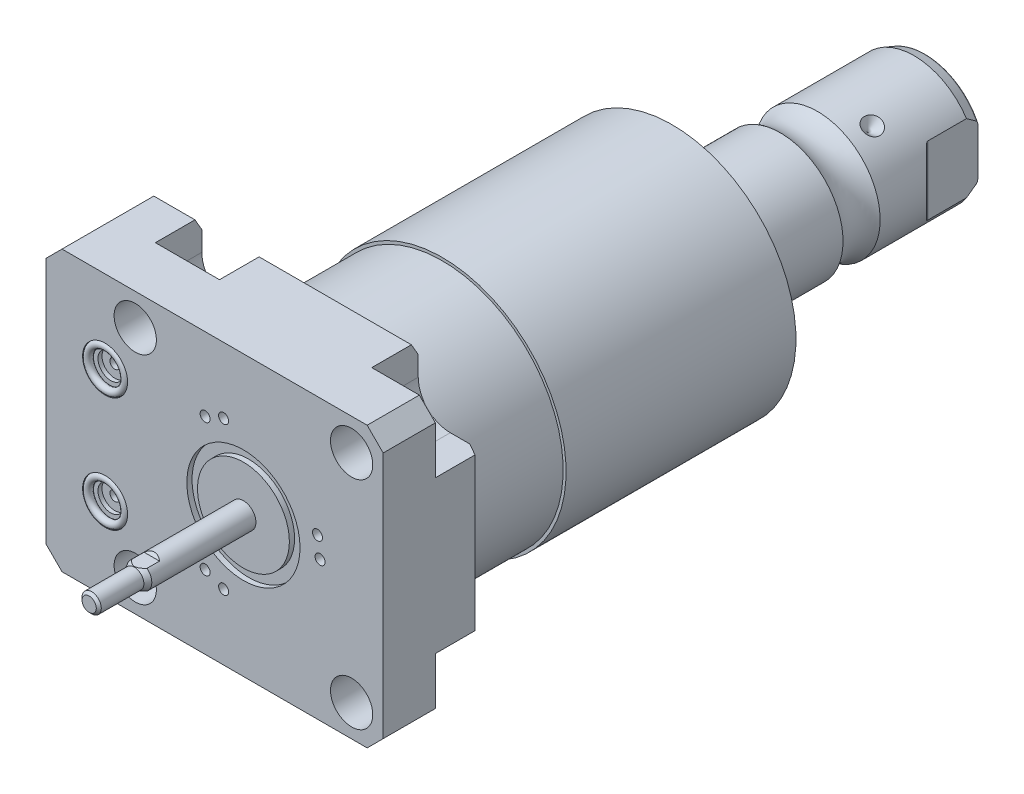
from build123d import *

# Parameters (mm, degrees)
SKETCH1_W                = 85.4964
SKETCH1_H                = 70.866
EXTRUDE1_DEPTH           = 25.019
SKETCH2_R                = 5.3594
CUT_EXTRUDE1_DEPTH       = 27.5209
LPATTERN1_COUNT          = 2
LPATTERN1_PITCH          = 54.864
LPATTERN1_COUNT_DIR2     = 2
LPATTERN1_PITCH_DIR2     = 54.864
CUT_EXTRUDE2_DEPTH       = 11.7856
SKETCH6_R                = 5.7023
CUT_EXTRUDE3_DEPTH       = 1.4478
SKETCH7_R                = 3.2512
CUT_EXTRUDE4_DEPTH       = 1.016
SKETCH8_R                = 1.2446
CUT_EXTRUDE5_DEPTH       = 11.9888
SKETCH9_R                = 0.9271
CHAMFER1_SIZE            = 4.064
CHAMFER2_SIZE            = 3.0226
CHAMFER2_SIZE2           = 1.745098924
SKETCH14_R               = 31.3944
EXTRUDE2_DEPTH           = 86.995
SKETCH15_OUTSIDE_W       = 119.1
SKETCH15_OUTSIDE_H       = 104.47
SKETCH15_OUTSIDE_R       = 30.6578
CUT_EXTRUDE9_DEPTH       = 25.4
CIRPATTERN1_COUNT        = 3
FILLET1_R                = 0.635
CUT_EXTRUDE12_DEPTH      = 36.433
CUT_EXTRUDE12_DEPTH_BACK = 36.433
SKETCH28_W               = 1.3208
SKETCH28_H               = 2.7051
CUT_EXTRUDE13_DEPTH      = 3.81
SKETCH30_R               = 1.27
CUT_EXTRUDE14_DEPTH      = 7.62


with BuildPart() as part:
    # Sketch1 → Extrude1 (new body)
    with BuildSketch(Plane.XY):
        with Locations((-7.3152, 0)):
            Rectangle(SKETCH1_W, SKETCH1_H)
    extrude(amount=EXTRUDE1_DEPTH)

    # Sketch2 → Cut-Extrude1 (cut)
    with BuildSketch(Plane(origin=(0, 0, 0), x_dir=(-1, 0, 0), z_dir=(0, 0, -1))):
        with Locations((-27.432, -27.432)):
            Circle(SKETCH2_R)
    cut_extrude1 = extrude(amount=-CUT_EXTRUDE1_DEPTH, mode=Mode.SUBTRACT)

    # LPattern1: Cut-Extrude1 2 × 2
    with Locations(*[(-j * LPATTERN1_PITCH_DIR2, i * LPATTERN1_PITCH, 0) for i in range(LPATTERN1_COUNT) for j in range(LPATTERN1_COUNT_DIR2) if (i, j) != (0, 0)]):
        add(cut_extrude1, mode=Mode.SUBTRACT)

    # Sketch3 → Cut-Extrude2 (cut)
    with BuildSketch(Plane(origin=(0, 0, 0), x_dir=(-1, 0, 0), z_dir=(0, 0, -1))):
        with BuildLine():
            Line((-27.432, -19.304), (-35.433, -19.304))
            Line((-35.433, -19.304), (-35.433, -35.433))
            Line((-35.433, -35.433), (-19.304, -35.433))
            Line((-19.304, -35.433), (-19.304, -27.432))
            ThreePointArc((-19.304, -27.432), (-21.684636083, -21.684636083), (-27.432, -19.304))
        make_face()
        with BuildLine():
            Line((-35.433, 19.304), (-35.433, 35.433))
            Line((-35.433, 35.433), (-19.304, 35.433))
            Line((-19.304, 35.433), (-19.304, 27.432))
            ThreePointArc((-19.304, 27.432), (-21.684636083, 21.684636083), (-27.432, 19.304))
            Line((-27.432, 19.304), (-35.433, 19.304))
        make_face()
        with BuildLine():
            Line((19.304, 35.433), (19.304, 27.432))
            ThreePointArc((19.304, 27.432), (27.432, 19.304), (35.56, 27.432))
            Line((35.56, 27.432), (35.56, 35.433))
            Line((35.56, 35.433), (19.304, 35.433))
        make_face()
        with BuildLine():
            Line((35.56, -35.433), (19.304, -35.433))
            Line((19.304, -35.433), (19.304, -27.432))
            ThreePointArc((19.304, -27.432), (27.432, -19.304), (35.56, -27.432))
            Line((35.56, -27.432), (35.56, -35.433))
        make_face()
    extrude(amount=-CUT_EXTRUDE2_DEPTH, mode=Mode.SUBTRACT)

    # S2D0007 → Cut-Revolve1 (revolve, cut)
    with BuildSketch(Plane(origin=(-55.5498, -13.0048, 12.5222), x_dir=(0, 1, 0), z_dir=(0, 0, 1)), mode=Mode.PRIVATE) as cut_revolve1_sk:
        Polygon((0, -5.4864), (10.4775, -5.4864), (10.4775, -5.7404), (6.1849, -5.7404), (5.642306865, -8.2931), (4.9784, -8.957006865), (4.9784, -19.7104), (0, -19.7104), align=None)
    cut_revolve1 = revolve(cut_revolve1_sk.sketch.rotate(Axis((-35.077219214, -13.0048, 12.5222), (-1, 0, 0)), 90), axis=Axis((-35.077219214, -13.0048, 12.5222), (-1, 0, 0)), mode=Mode.SUBTRACT)  # turned: the seam where the file's is

    # Mirror1: Cut-Revolve1 across plane
    add(cut_revolve1.mirror(Plane.ZX), mode=Mode.SUBTRACT)

    # Sketch6 → Cut-Extrude3 (cut)
    with BuildSketch(Plane.XY.offset(25.019)):
        with Locations((-35.0774, -14.5288)):
            Circle(SKETCH6_R)
        with Locations((-35.0774, 14.5288)):
            Circle(SKETCH6_R)
    extrude(amount=-CUT_EXTRUDE3_DEPTH, mode=Mode.SUBTRACT)

    # Sketch7 → Cut-Extrude4 (cut)
    with BuildSketch(Plane.XY.offset(23.5712)):
        with Locations((-35.0774, 14.5288)):
            Circle(SKETCH7_R)
        with Locations((-35.0774, -14.5288)):
            Circle(SKETCH7_R)
    extrude(amount=-CUT_EXTRUDE4_DEPTH, mode=Mode.SUBTRACT)

    # Sketch8 → Cut-Extrude5 (cut)
    with BuildSketch(Plane.XY.offset(22.5552)):
        with Locations((-35.0774, 14.5288)):
            Circle(SKETCH8_R)
        with Locations((-35.0774, -14.5288)):
            Circle(SKETCH8_R)
    extrude(amount=-CUT_EXTRUDE5_DEPTH, mode=Mode.SUBTRACT)

    # Chamfer1
    chamfer1_edges = [part.edges().sort_by_distance(p)[0] for p in [
        (-50.0634, 35.433, 12.5095),
        (35.433, 35.433, 18.4023),
        (35.433, -35.433, 18.4023),
        (-50.0634, -35.433, 12.5095),
    ]]
    chamfer(chamfer1_edges, length=CHAMFER1_SIZE)

    # Chamfer2
    chamfer2_edges = [part.edges().sort_by_distance(p)[0] for p in [
        (-40.7797, -35.433, 0),
        (35.433, 0, 0),
        (0, 35.433, 0),
        (-40.7797, 35.433, 0),
        (0, -35.433, 0),
    ]]
    chamfer2_side = [part.faces().sort_by_distance(p)[0] for p in [
        (-8.721448678, 0, 0),
    ]]
    chamfer(chamfer2_edges, length=CHAMFER2_SIZE, length2=CHAMFER2_SIZE2, reference=chamfer2_side[0])

    # Sketch14 → Extrude2 (add)
    with BuildSketch(Plane(origin=(0, 0, 0), x_dir=(-1, 0, 0), z_dir=(0, 0, -1))):
        with Locations(Location((0, 0, 0), (0, 0, 140.520960584))):  # turned: the seam where the file's is
            Circle(SKETCH14_R)
    extrude(amount=EXTRUDE2_DEPTH)

    # Sketch15 outside → Cut-Extrude9 (cut)
    with BuildSketch(Plane(origin=(0, 0, 0), x_dir=(-1, 0, 0), z_dir=(0, 0, -1))):
        with Locations((7.315, 0)):
            Rectangle(SKETCH15_OUTSIDE_W, SKETCH15_OUTSIDE_H)
        Circle(SKETCH15_OUTSIDE_R, mode=Mode.SUBTRACT)
    extrude(amount=CUT_EXTRUDE9_DEPTH, mode=Mode.SUBTRACT)

    # Sketch16 → Cut-Revolve3 (revolve, cut)
    with BuildSketch(Plane(origin=(0, 0, 0), x_dir=(0, 0, 1), z_dir=(1, 0, 0)), mode=Mode.PRIVATE) as cut_revolve3_sk:
        Polygon((-86.995, 19.05), (-83.687327989, 31.3944), (-86.995, 31.3944), align=None)
    revolve(cut_revolve3_sk.sketch.rotate(Axis((0, 0, -96.582204284), (0, 0, 1)), 270), axis=Axis((0, 0, -96.582204284), (0, 0, 1)), mode=Mode.SUBTRACT)  # turned: the seam where the file's is

    # Sketch17 → Revolve3 (revolve)
    with BuildSketch(Plane(origin=(0, 0, 0), x_dir=(0, 0, 1), z_dir=(1, 0, 0)), mode=Mode.PRIVATE) as revolve3_sk:
        with BuildLine():
            Line((-86.995, 0), (-86.995, 15.875))
            Line((-86.995, 15.875), (-111.14230643, 15.875))
            ThreePointArc((-111.14230643, 15.875), (-115.8494, 14.3256), (-120.55649357, 15.875))
            Line((-120.55649357, 15.875), (-145.034, 15.875))
            Line((-145.034, 15.875), (-147.955, 14.811842946))
            Line((-147.955, 14.811842946), (-147.955, 0))
            Line((-147.955, 0), (-86.995, 0))
        make_face()
    revolve(revolve3_sk.sketch.rotate(Axis((0, 0, -180.9369), (0, 0, 1)), 270), axis=Axis((0, 0, -180.9369), (0, 0, 1)))  # turned: the seam where the file's is

    # Sketch22 → Cut-Revolve4 (revolve, cut)
    with BuildSketch(Plane(origin=(0, 0, 0), x_dir=(1, 0, 0), z_dir=(0, 1, 0)), mode=Mode.PRIVATE) as cut_revolve4_sk:
        Polygon((-15.875, 128.9304), (-15.875, 126.5174), (-13.462, 126.5174), align=None)
    cut_revolve4 = revolve(cut_revolve4_sk.sketch.rotate(Axis((-21.668802649, 0, -126.5174), (1, 0, 0)), 180), axis=Axis((-21.668802649, 0, -126.5174), (1, 0, 0)), mode=Mode.SUBTRACT)  # turned: the seam where the file's is

    # CirPattern1: Cut-Revolve4 ×3 about axis
    cirpattern1_axis = Axis((0, 0, -180.9369), (0, 0, -1))
    for i in range(1, CIRPATTERN1_COUNT):
        add(cut_revolve4.rotate(cirpattern1_axis, i * 360 / CIRPATTERN1_COUNT), mode=Mode.SUBTRACT)

    # Fillet1
    fillet1_edges = [part.edges().sort_by_distance(p)[0] for p in [
        (14.811842946, 0, -147.955),
    ]]
    fillet(fillet1_edges, radius=FILLET1_R)

    # Sketch24 → Hole1 (revolve, cut)
    with BuildSketch(Plane(origin=(0, 0, -147.955), x_dir=(0, 1, 0), z_dir=(1, 0, 0))):
        Polygon((0, 0), (0, 25.399999974), (6.9342, 21.23351227), (6.9342, 0), align=None)
    revolve(axis=Axis((0, 0, -152.199199587), (0, 0, 1)), mode=Mode.SUBTRACT)

    # Sketch26 → Cut-Extrude12 (cut, two sides)
    with BuildSketch(Plane(origin=(0, 0, 0), x_dir=(1, 0, 0), z_dir=(0, 1, 0))) as cut_extrude12_sk:
        with BuildLine():
            Line((-13.2842, 147.955), (-13.2842, 135.255))
            ThreePointArc((-13.2842, 135.255), (-13.342203796, 134.963395225), (-13.507384633, 134.716184633))
            Line((-13.507384633, 134.716184633), (-15.875, 132.348569265))
            Line((-15.875, 132.348569265), (-15.875, 147.955))
            Line((-15.875, 147.955), (-13.2842, 147.955))
        make_face()
        with BuildLine():
            Line((15.875, 147.955), (13.2842, 147.955))
            Line((13.2842, 147.955), (13.2842, 135.255))
            ThreePointArc((13.2842, 135.255), (13.342203796, 134.963395225), (13.507384633, 134.716184633))
            Line((13.507384633, 134.716184633), (15.875, 132.348569265))
            Line((15.875, 132.348569265), (15.875, 147.955))
        make_face()
    extrude(amount=CUT_EXTRUDE12_DEPTH, mode=Mode.SUBTRACT)
    extrude(cut_extrude12_sk.sketch, amount=-CUT_EXTRUDE12_DEPTH_BACK, mode=Mode.SUBTRACT)

    # Sketch27 → Revolve4 (revolve)
    with BuildSketch(Plane(origin=(0, 0, 0), x_dir=(0, 0, -1), z_dir=(1, 0, 0)), mode=Mode.PRIVATE) as revolve4_sk:
        Polygon((-25.019, 0), (-25.019, -3.175), (-51.429171375, -3.175), (-52.705, -2.4384), (-63.5, -2.4384), (-64.135, -1.8034), (-64.135, 0), align=None)
    revolve(revolve4_sk.sketch.rotate(Axis((0, 0, 1000), (0, 0, -1)), 90), axis=Axis((0, 0, 1000), (0, 0, -1)))  # turned: the seam where the file's is

    # Sketch28 → Cut-Revolve5 (revolve, cut)
    with BuildSketch(Plane(origin=(0, 0, 0), x_dir=(0, 0, -1), z_dir=(1, 0, 0)), mode=Mode.PRIVATE) as cut_revolve5_sk:
        with Locations((-24.3586, -12.99845)):
            Rectangle(SKETCH28_W, SKETCH28_H)
    revolve(cut_revolve5_sk.sketch.rotate(Axis((0, 0, 1000), (0, 0, -1)), 90), axis=Axis((0, 0, 1000), (0, 0, -1)), mode=Mode.SUBTRACT)  # turned: the seam where the file's is

    # Sketch29 → Cut-Extrude13 (cut, symmetric)
    with BuildSketch(Plane(origin=(0, 0, 0), x_dir=(0, 0, -1), z_dir=(1, 0, 0))):
        Polygon((-47.5869, -3.175), (-48.26, -2.5019), (-64.135, -2.5019), (-64.135, -3.175), align=None)
        Polygon((-47.5869, 3.175), (-48.26, 2.5019), (-64.135, 2.5019), (-64.135, 3.175), align=None)
    extrude(amount=CUT_EXTRUDE13_DEPTH, both=True, mode=Mode.SUBTRACT)

    # Sketch30 → Cut-Extrude14 (cut)
    with BuildSketch(Plane.XY.offset(25.019)):
        with Locations((19.431, 0)):
            Circle(SKETCH30_R)
        with Locations((18.768904731, 5.029112865)):
            Circle(SKETCH30_R)
        with Locations(Location((-5.029112865, 18.768904731, 0), (0, 0, 180))):  # turned: the seam where the file's is
            Circle(SKETCH30_R)
        with Locations(Location((-9.7155, 16.827739621, 0), (0, 0, 180))):  # turned: the seam where the file's is
            Circle(SKETCH30_R)
        with Locations((-9.7155, -16.827739621)):
            Circle(SKETCH30_R)
        with Locations((-5.029112865, -18.768904731)):
            Circle(SKETCH30_R)
    extrude(amount=-CUT_EXTRUDE14_DEPTH, mode=Mode.SUBTRACT)


with BuildPart() as body_2:
    # Sketch9 → Revolve1 (revolve)
    with BuildSketch(Plane(origin=(-41.656, -14.5288, 23.5712), x_dir=(1, 0, 0), z_dir=(0, 1, 0))):
        with Locations((11.3538, -0.9271)):
            Circle(SKETCH9_R)
    revolve(axis=Axis((-35.0774, -14.5288, 25.51811), (0, 0, -1)))


with BuildPart() as body_3:
    # Mirror2: mirrored copy
    add(body_2.part.mirror(Plane.ZX))


solid = Compound([part.part, body_2.part, body_3.part])
